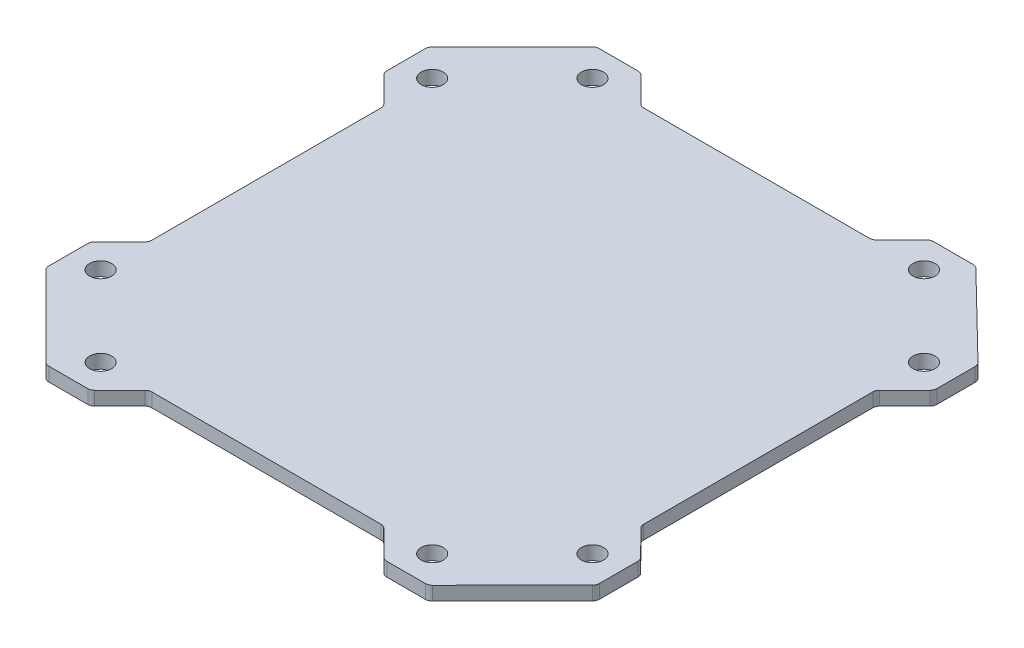
from build123d import *

# Parameters (mm, degrees)
ESQUISSE1_R        = 8
BOSS_EXTRU_3_DEPTH = 10


with BuildPart() as part:
    # Esquisse1 → Boss.-Extru.3 (new body)
    with BuildSketch(Plane(origin=(0, 0, 0), x_dir=(1, 0, 0), z_dir=(0, 1, 0))):
        with BuildLine():
            Line((-198.535533906, 140.467889787), (-140.467889787, 198.535533906))
            ThreePointArc((-140.467889787, 198.535533906), (-138.845773043, 199.619397663), (-136.932355881, 200))
            Line((-136.932355881, 200), (-108.642059072, 200))
            ThreePointArc((-108.642059072, 200), (-106.728641911, 199.619397663), (-105.106525166, 198.535533906))
            Line((-105.106525166, 198.535533906), (-86.822253919, 180.251262659))
            ThreePointArc((-86.822253919, 180.251262659), (-85.200137175, 179.167398902), (-83.286720013, 178.786796564))
            Line((-83.286720013, 178.786796564), (80.808477816, 178.786796564))
            ThreePointArc((80.808477816, 178.786796564), (82.721894978, 179.167398902), (84.344011722, 180.251262659))
            Line((84.344011722, 180.251262659), (102.628282969, 198.535533906))
            ThreePointArc((102.628282969, 198.535533906), (104.250399713, 199.619397663), (106.163816875, 200))
            Line((106.163816875, 200), (134.922487193, 200))
            ThreePointArc((134.922487193, 200), (136.805633434, 199.631820402), (138.411445264, 198.581504094))
            Line((138.411445264, 198.581504094), (198.488958072, 140.056393487))
            ThreePointArc((198.488958072, 140.056393487), (199.606777092, 138.418495531), (200, 136.474889393))
            Line((200, 136.474889393), (200, 108.642059072))
            ThreePointArc((200, 108.642059072), (199.619397663, 106.728641911), (198.535533906, 105.106525167))
            Line((198.535533906, 105.106525167), (180.251262658, 86.822253919))
            ThreePointArc((180.251262658, 86.822253919), (179.167398902, 85.200137175), (178.786796564, 83.286720013))
            Line((178.786796564, 83.286720013), (178.786796564, -83.293766644))
            ThreePointArc((178.786796564, -83.293766644), (179.165099385, -85.201622818), (180.242762637, -86.820780044))
            Line((180.242762637, -86.820780044), (198.544033927, -105.210368915))
            ThreePointArc((198.544033927, -105.210368915), (199.621697179, -106.82952614), (200, -108.737382314))
            Line((200, -108.737382314), (200, -136.645047547))
            ThreePointArc((200, -136.645047547), (199.621697179, -138.552903722), (198.544033927, -140.172060947))
            Line((198.544033927, -140.172060947), (140.469336148, -198.5270134))
            ThreePointArc((140.469336148, -198.5270134), (138.844277599, -199.617091455), (136.925302221, -200))
            Line((136.925302221, -200), (108.737382314, -200))
            ThreePointArc((108.737382314, -200), (106.82952614, -199.621697179), (105.210368915, -198.544033927))
            Line((105.210368915, -198.544033927), (86.820780044, -180.242762637))
            ThreePointArc((86.820780044, -180.242762637), (85.201622818, -179.165099385), (83.293766644, -178.786796564))
            Line((83.293766644, -178.786796564), (-83.286720013, -178.786796564))
            ThreePointArc((-83.286720013, -178.786796564), (-85.200137175, -179.167398902), (-86.822253919, -180.251262658))
            Line((-86.822253919, -180.251262658), (-105.106525166, -198.535533906))
            ThreePointArc((-105.106525166, -198.535533906), (-106.728641911, -199.619397663), (-108.642059072, -200))
            Line((-108.642059072, -200), (-136.932355881, -200))
            ThreePointArc((-136.932355881, -200), (-138.845773043, -199.619397663), (-140.467889787, -198.535533906))
            Line((-140.467889787, -198.535533906), (-198.535533906, -140.467889787))
            ThreePointArc((-198.535533906, -140.467889787), (-199.619397663, -138.845773043), (-200, -136.932355881))
            Line((-200, -136.932355881), (-200, -108.642059072))
            ThreePointArc((-200, -108.642059072), (-199.619397663, -106.728641911), (-198.535533906, -105.106525166))
            Line((-198.535533906, -105.106525166), (-180.251262658, -86.822253919))
            ThreePointArc((-180.251262658, -86.822253919), (-179.167398902, -85.200137175), (-178.786796564, -83.286720013))
            Line((-178.786796564, -83.286720013), (-178.786796564, 83.286720013))
            ThreePointArc((-178.786796564, 83.286720013), (-179.167398902, 85.200137175), (-180.251262658, 86.822253919))
            Line((-180.251262658, 86.822253919), (-198.535533906, 105.106525166))
            ThreePointArc((-198.535533906, 105.106525166), (-199.619397663, 106.728641911), (-200, 108.642059072))
            Line((-200, 108.642059072), (-200, 136.932355881))
            ThreePointArc((-200, 136.932355881), (-199.619397663, 138.845773043), (-198.535533906, 140.467889787))
        make_face()
        with Locations(Location((120.524036122, -178.786796564, 0), (0, 0, 270))):  # turned: the seam where the file's is
            Circle(ESQUISSE1_R, mode=Mode.SUBTRACT)
        with Locations(Location((-178.786796564, -120.524036122, 0), (0, 0, 270))):  # turned: the seam where the file's is
            Circle(ESQUISSE1_R, mode=Mode.SUBTRACT)
        with Locations(Location((-120.524036122, 178.786796564, 0), (0, 0, 270))):  # turned: the seam where the file's is
            Circle(ESQUISSE1_R, mode=Mode.SUBTRACT)
        with Locations(Location((178.786796564, 120.524036122, 0), (0, 0, 270))):  # turned: the seam where the file's is
            Circle(ESQUISSE1_R, mode=Mode.SUBTRACT)
        with Locations(Location((-178.786796564, 120.524036122, 0), (0, 0, 90))):  # turned: the seam where the file's is
            Circle(ESQUISSE1_R, mode=Mode.SUBTRACT)
        with Locations(Location((120.524036122, 178.786796564, 0), (0, 0, 90))):  # turned: the seam where the file's is
            Circle(ESQUISSE1_R, mode=Mode.SUBTRACT)
        with Locations(Location((178.786796564, -120.524036122, 0), (0, 0, 90))):  # turned: the seam where the file's is
            Circle(ESQUISSE1_R, mode=Mode.SUBTRACT)
        with Locations(Location((-120.524036122, -178.786796564, 0), (0, 0, 90))):  # turned: the seam where the file's is
            Circle(ESQUISSE1_R, mode=Mode.SUBTRACT)
    extrude(amount=-BOSS_EXTRU_3_DEPTH)


solid = part.part
